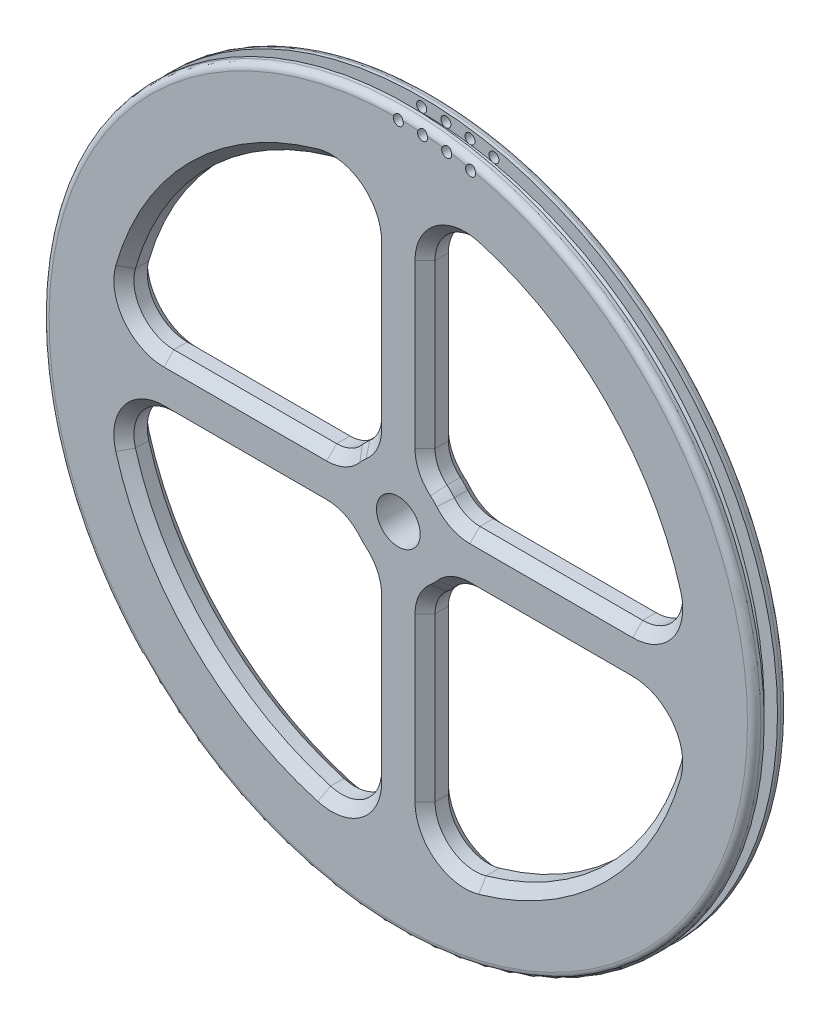
from build123d import *

# Parameters (mm, degrees)
SKETCH2_R           = 50.8
BOSS_EXTRUDE2_DEPTH = 2
SKETCH3_R           = 53.3
BOSS_EXTRUDE3_DEPTH = 1.5
CHAMFER1_SIZE       = 0.5
CUT_EXTRUDE1_DEPTH  = 6
FILLET1_R           = 6
FILLET2_R           = 5
CHAMFER2_SIZE       = 1.5
FILLET3_R           = 1
SKETCH5_R           = 0.75
CUT_EXTRUDE2_DEPTH  = 6


with BuildPart() as part:
    # Sketch2 → Boss-Extrude2 (new body)
    with BuildSketch(Plane.XY):
        Circle(SKETCH2_R)
    extrude(amount=BOSS_EXTRUDE2_DEPTH)

    # Sketch3 → Boss-Extrude3 (add)
    with BuildSketch(Plane.XY.offset(2)):
        Circle(SKETCH3_R)
    boss_extrude3 = extrude(amount=BOSS_EXTRUDE3_DEPTH)

    # Mirror2: Boss-Extrude3 across plane
    add(boss_extrude3.mirror(Plane(origin=(0, 0, 1), x_dir=(1, 0, 0), z_dir=(0, 0, -1))))

    # Chamfer1
    chamfer1_edges = [part.edges().sort_by_distance(p)[0] for p in [
        (-50.8, 0, 2),
        (-50.8, 0, 0),
    ]]
    chamfer(chamfer1_edges, length=CHAMFER1_SIZE)

    # Sketch4 → Cut-Extrude1 (cut, through all)
    with BuildSketch(Plane(origin=(0, 0, -1.5), x_dir=(-1, 0, 0), z_dir=(0, 0, -1))):
        with BuildLine():
            Line((-42.311345996, 4), (-8.062257748, 4))
            ThreePointArc((-8.062257748, 4), (-6.363961031, 6.363961031), (-4, 8.062257748))
            Line((-4, 8.062257748), (-4, 42.311345996))
            ThreePointArc((-4, 42.311345996), (-30.0520382, 30.0520382), (-42.311345996, 4))
        make_face()
        with BuildLine():
            Line((4, 42.311345996), (4, 8.062257748))
            ThreePointArc((4, 8.062257748), (6.363961031, 6.363961031), (8.062257748, 4))
            Line((8.062257748, 4), (42.311345996, 4))
            ThreePointArc((42.311345996, 4), (30.0520382, 30.0520382), (4, 42.311345996))
        make_face()
        with BuildLine():
            Line((42.311345996, -4), (8.062257748, -4))
            ThreePointArc((8.062257748, -4), (6.363961031, -6.363961031), (4, -8.062257748))
            Line((4, -8.062257748), (4, -42.311345996))
            ThreePointArc((4, -42.311345996), (30.0520382, -30.0520382), (42.311345996, -4))
        make_face()
        with BuildLine():
            Line((-4, -42.311345996), (-4, -8.062257748))
            ThreePointArc((-4, -8.062257748), (-6.363961031, -6.363961031), (-8.062257748, -4))
            Line((-8.062257748, -4), (-42.311345996, -4))
            ThreePointArc((-42.311345996, -4), (-30.0520382, -30.0520382), (-4, -42.311345996))
        make_face()
        with BuildLine():
            Line((3.275, 0), (0, 0))
            Line((0, 0), (0, -3.275))
            ThreePointArc((0, -3.275), (2.315774708, -2.315774708), (3.275, 0))
        make_face()
        with BuildLine():
            Line((0, 3.275), (0, 0))
            Line((0, 0), (3.275, 0))
            ThreePointArc((3.275, 0), (2.315774708, 2.315774708), (0, 3.275))
        make_face()
        with BuildLine():
            Line((-3.275, 0), (0, 0))
            Line((0, 0), (0, 3.275))
            ThreePointArc((0, 3.275), (-2.315774708, 2.315774708), (-3.275, 0))
        make_face()
        with BuildLine():
            Line((0, -3.275), (0, 0))
            Line((0, 0), (-3.275, 0))
            ThreePointArc((-3.275, 0), (-2.315774708, -2.315774708), (0, -3.275))
        make_face()
    extrude(amount=-CUT_EXTRUDE1_DEPTH, mode=Mode.SUBTRACT)

    # Fillet1
    fillet1_edges = [part.edges().sort_by_distance(p)[0] for p in [
        (42.311345996, -4, 1),
        (4, -42.311345996, 1),
        (-4, -42.311345996, 1),
        (-42.311345996, -4, 1),
        (-42.311345996, 4, 1),
        (-4, 42.311345996, 1),
        (4, 42.311345996, 1),
        (42.311345996, 4, 1),
    ]]
    fillet(fillet1_edges, radius=FILLET1_R)

    # Fillet2
    fillet2_edges = [part.edges().sort_by_distance(p)[0] for p in [
        (8.062257748, -4, 1),
        (4, -8.062257748, 1),
        (-4, -8.062257748, 1),
        (-8.062257748, -4, 1),
        (-8.062257748, 4, 1),
        (-4, 8.062257748, 1),
        (4, 8.062257748, 1),
        (8.062257748, 4, 1),
    ]]
    fillet(fillet2_edges, radius=FILLET2_R)

    # Chamfer2
    chamfer2_edges = [part.edges().sort_by_distance(p)[0] for p in [
        (-6.384962912, 39.892103931, -1.5),
        (-6.384962912, 39.892103931, 3.5),
        (-39.892103931, 6.384962912, -1.5),
        (-39.892103931, 6.384962912, 3.5),
        (-39.892103931, -6.384962912, -1.5),
        (-39.892103931, -6.384962912, 3.5),
        (-6.384962912, -39.892103931, -1.5),
        (-6.384962912, -39.892103931, 3.5),
        (6.384962912, -39.892103931, -1.5),
        (6.384962912, -39.892103931, 3.5),
        (39.892103931, -6.384962912, -1.5),
        (39.892103931, -6.384962912, 3.5),
        (39.892103931, 6.384962912, -1.5),
        (39.892103931, 6.384962912, 3.5),
        (6.384962912, 39.892103931, -1.5),
        (6.384962912, 39.892103931, 3.5),
        (-4, -22.913611966, -1.5),
        (-4, -22.913611966, 3.5),
        (-6.363961031, -6.363961031, -1.5),
        (-6.363961031, -6.363961031, 3.5),
        (-22.913611966, -4, 3.5),
        (-22.913611966, -4, -1.5),
        (-22.913611966, 4, -1.5),
        (-22.913611966, 4, 3.5),
        (-6.363961031, 6.363961031, -1.5),
        (-6.363961031, 6.363961031, 3.5),
        (-4, 22.913611966, 3.5),
        (-4, 22.913611966, -1.5),
        (6.363961031, 6.363961031, -1.5),
        (6.363961031, 6.363961031, 3.5),
        (22.913611966, 4, 3.5),
        (22.913611966, 4, -1.5),
        (4, 22.913611966, -1.5),
        (4, 22.913611966, 3.5),
        (6.363961031, -6.363961031, -1.5),
        (6.363961031, -6.363961031, 3.5),
        (4, -22.913611966, 3.5),
        (4, -22.913611966, -1.5),
        (22.913611966, -4, -1.5),
        (22.913611966, -4, 3.5),
        (-4.468365164, -8.610919658, -1.5),
        (-4.468365164, -8.610919658, 3.5),
        (-8.610919658, -4.468365164, -1.5),
        (-8.610919658, -4.468365164, 3.5),
        (-8.610919658, 4.468365164, -1.5),
        (-8.610919658, 4.468365164, 3.5),
        (-4.468365164, 8.610919658, -1.5),
        (-4.468365164, 8.610919658, 3.5),
        (8.610919658, 4.468365164, -1.5),
        (8.610919658, 4.468365164, 3.5),
        (4.468365164, 8.610919658, -1.5),
        (4.468365164, 8.610919658, 3.5),
        (4.468365164, -8.610919658, -1.5),
        (4.468365164, -8.610919658, 3.5),
        (8.610919658, -4.468365164, -1.5),
        (8.610919658, -4.468365164, 3.5),
        (-30.0520382, 30.0520382, -1.5),
        (-30.0520382, 30.0520382, 3.5),
        (-30.0520382, -30.0520382, -1.5),
        (-30.0520382, -30.0520382, 3.5),
        (30.0520382, -30.0520382, -1.5),
        (30.0520382, -30.0520382, 3.5),
        (30.0520382, 30.0520382, -1.5),
        (30.0520382, 30.0520382, 3.5),
    ]]
    chamfer(chamfer2_edges, length=CHAMFER2_SIZE)

    # Fillet3
    fillet3_edges = [part.edges().sort_by_distance(p)[0] for p in [
        (-53.3, 0, 3.5),
        (-53.3, 0, -1.5),
    ]]
    fillet(fillet3_edges, radius=FILLET3_R)

    # Sketch5 → Cut-Extrude2 (cut, through all)
    with BuildSketch(Plane.XY.offset(3.5)):
        with Locations((0, 52.05)):
            Circle(SKETCH5_R)
        with Locations((3.630824458, 51.923208816)):
            Circle(SKETCH5_R)
        with Locations((7.243959905, 51.543452978)):
            Circle(SKETCH5_R)
        with Locations((10.821803507, 50.912582618)):
            Circle(SKETCH5_R)
    extrude(amount=-CUT_EXTRUDE2_DEPTH, mode=Mode.SUBTRACT)


solid = part.part
